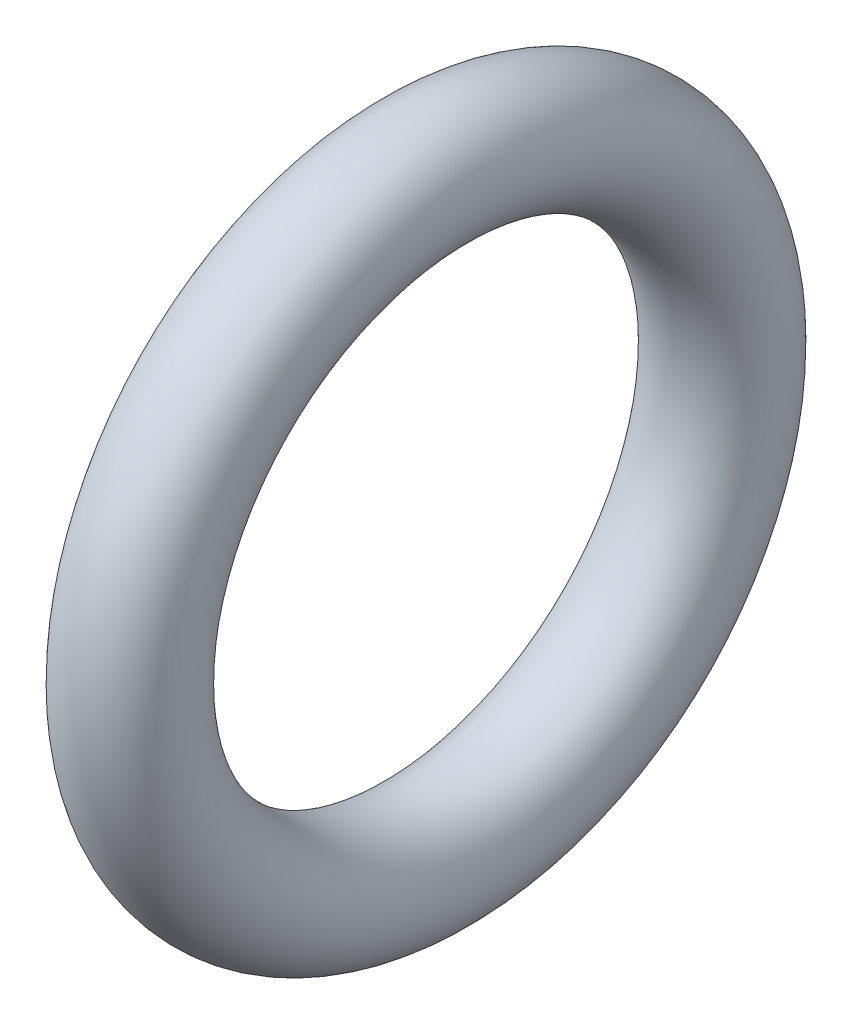
from build123d import *

# Parameters (mm, degrees)
SKETCH1_R = 1.190625


with BuildPart() as part:
    # Sketch1 → Revolve2 (revolve)
    with BuildSketch(Plane.XY):
        with Locations((0, 5.950625)):
            Circle(SKETCH1_R)
    revolve(axis=Axis((-3.180246236, 0, 0), (1, 0, 0)))


solid = part.part
